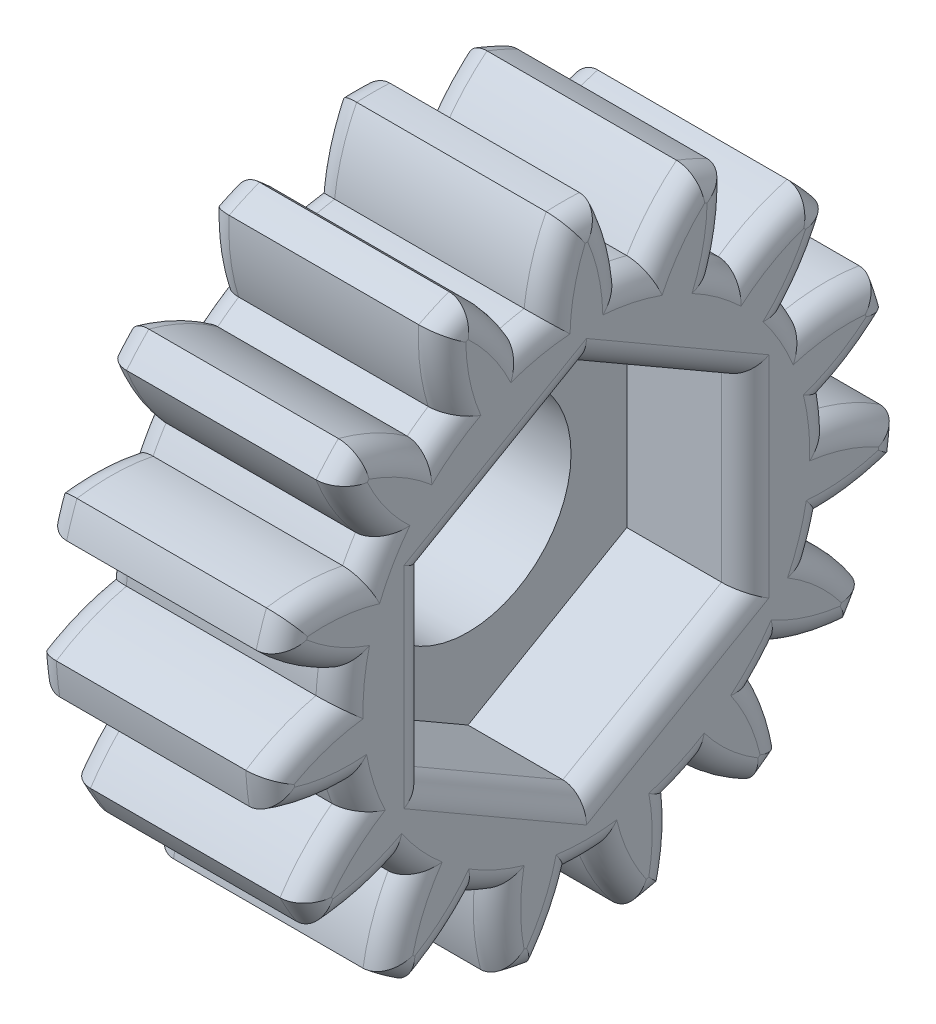
from build123d import *

# Parameters (mm, degrees)
SALIENTE_EXTRUIR1_DEPTH = 10
CORTAR_EXTRUIR1_DEPTH   = 5
CROQUIS1_4_R            = 4.35
CORTAR_EXTRUIR2_DEPTH   = 22.415605893
REDONDEO1_R             = 1


with BuildPart() as part:
    # Croquis1 → Saliente-Extruir1 (new body)
    with BuildSketch(Plane(origin=(0, 0, 0), x_dir=(0, 0, -1), z_dir=(1, 0, 0))):
        with BuildLine():
            ThreePointArc((-10.303317847, 1.631885231), (-10.374603782, 1.090414797), (-10.417453649, 0.545955612))
            ThreePointArc((-10.417453649, 0.545955612), (-11.954971432, 0.054051837), (-13.381635766, -0.701301814))
            ThreePointArc((-13.381635766, -0.701301814), (-13.326593398, -1.400681408), (-13.235023764, -2.096221832))
            ThreePointArc((-13.235023764, -2.096221832), (-11.682488615, -2.538448999), (-10.076296738, -2.699935574))
            ThreePointArc((-10.076296738, -2.699935574), (-9.921183814, -3.223588031), (-9.738877614, -3.738404858))
            ThreePointArc((-9.738877614, -3.738404858), (-10.943394711, -4.813146138), (-11.939487424, -6.083472697))
            ThreePointArc((-11.939487424, -6.083472697), (-11.604740411, -6.7), (-11.23818561, -7.298163069))
            ThreePointArc((-11.23818561, -7.298163069), (-9.640004184, -7.070684754), (-8.106992383, -6.564912989))
            ThreePointArc((-8.106992383, -6.564912989), (-7.752301033, -6.980203203), (-7.376361165, -7.376361165))
            ThreePointArc((-7.376361165, -7.376361165), (-8.039605626, -8.84810742), (-8.43289324, -10.413755884))
            ThreePointArc((-8.43289324, -10.413755884), (-7.876322381, -10.840827725), (-7.298163069, -11.23818561))
            ThreePointArc((-7.298163069, -11.23818561), (-5.930675452, -10.38033488), (-4.735915396, -9.294757309))
            ThreePointArc((-4.735915396, -9.294757309), (-4.242974976, -9.529877828), (-3.738404858, -9.738877614))
            ThreePointArc((-3.738404858, -9.738877614), (-3.745695692, -11.353150547), (-3.468175204, -12.943406072))
            ThreePointArc((-3.468175204, -12.943406072), (-2.786016657, -13.10717785), (-2.096221832, -13.235023764))
            ThreePointArc((-2.096221832, -13.235023764), (-1.195879057, -11.895130803), (-0.545955612, -10.417453649))
            ThreePointArc((-0.545955612, -10.417453649), (0, -10.43175), (0.545955612, -10.417453649))
            ThreePointArc((0.545955612, -10.417453649), (1.195879057, -11.895130803), (2.096221832, -13.235023764))
            ThreePointArc((2.096221832, -13.235023764), (2.786016657, -13.10717785), (3.468175204, -12.943406072))
            ThreePointArc((3.468175204, -12.943406072), (3.745695692, -11.353150547), (3.738404858, -9.738877614))
            ThreePointArc((3.738404858, -9.738877614), (4.242974976, -9.529877828), (4.735915396, -9.294757309))
            ThreePointArc((4.735915396, -9.294757309), (5.930675452, -10.38033488), (7.298163069, -11.23818561))
            ThreePointArc((7.298163069, -11.23818561), (7.876322381, -10.840827725), (8.43289324, -10.413755884))
            ThreePointArc((8.43289324, -10.413755884), (8.039605626, -8.84810742), (7.376361165, -7.376361165))
            ThreePointArc((7.376361165, -7.376361165), (7.752301033, -6.980203203), (8.106992383, -6.564912989))
            ThreePointArc((8.106992383, -6.564912989), (9.640004184, -7.070684754), (11.23818561, -7.298163069))
            ThreePointArc((11.23818561, -7.298163069), (11.604740411, -6.7), (11.939487424, -6.083472697))
            ThreePointArc((11.939487424, -6.083472697), (10.943394711, -4.813146138), (9.738877614, -3.738404858))
            ThreePointArc((9.738877614, -3.738404858), (9.921183814, -3.223588031), (10.076296738, -2.699935574))
            ThreePointArc((10.076296738, -2.699935574), (11.682488615, -2.538448999), (13.235023764, -2.096221832))
            ThreePointArc((13.235023764, -2.096221832), (13.326593398, -1.400681408), (13.381635766, -0.701301814))
            ThreePointArc((13.381635766, -0.701301814), (11.954971432, 0.054051837), (10.417453649, 0.545955612))
            ThreePointArc((10.417453649, 0.545955612), (10.374603782, 1.090414797), (10.303317847, 1.631885231))
            ThreePointArc((10.303317847, 1.631885231), (11.704964632, 2.43270765), (12.943406072, 3.468175204))
            ThreePointArc((12.943406072, 3.468175204), (12.744157318, 4.140827725), (12.509977715, 4.802130524))
            ThreePointArc((12.509977715, 4.802130524), (10.899424986, 4.911903759), (9.294757309, 4.735915396))
            ThreePointArc((9.294757309, 4.735915396), (9.034160506, 5.215875), (8.748801697, 5.681538254))
            ThreePointArc((8.748801697, 5.681538254), (9.703545929, 6.983227045), (10.413755884, 8.43289324))
            ThreePointArc((10.413755884, 8.43289324), (9.958140661, 8.966350125), (9.475230868, 9.475230868))
            ThreePointArc((9.475230868, 9.475230868), (7.959268941, 8.920442897), (6.564912989, 8.106992383))
            ThreePointArc((6.564912989, 8.106992383), (6.131628806, 8.439463031), (5.681538254, 8.748801697))
            ThreePointArc((5.681538254, 8.748801697), (6.02429598, 10.326283044), (6.083472697, 11.939487424))
            ThreePointArc((6.083472697, 11.939487424), (5.450271017, 12.241509132), (4.802130524, 12.509977715))
            ThreePointArc((4.802130524, 12.509977715), (3.642882988, 11.386556419), (2.699935574, 10.076296738))
            ThreePointArc((2.699935574, 10.076296738), (2.168882781, 10.203791234), (1.631885231, 10.303317847))
            ThreePointArc((1.631885231, 10.303317847), (1.303390528, 11.883830893), (0.701301814, 13.381635766))
            ThreePointArc((0.701301814, 13.381635766), (0, 13.4), (-0.701301814, 13.381635766))
            ThreePointArc((-0.701301814, 13.381635766), (-1.303390528, 11.883830893), (-1.631885231, 10.303317847))
            ThreePointArc((-1.631885231, 10.303317847), (-2.168882781, 10.203791234), (-2.699935574, 10.076296738))
            ThreePointArc((-2.699935574, 10.076296738), (-3.642882988, 11.386556419), (-4.802130524, 12.509977715))
            ThreePointArc((-4.802130524, 12.509977715), (-5.450271017, 12.241509132), (-6.083472697, 11.939487424))
            ThreePointArc((-6.083472697, 11.939487424), (-6.02429598, 10.326283044), (-5.681538254, 8.748801697))
            ThreePointArc((-5.681538254, 8.748801697), (-6.131628806, 8.439463031), (-6.564912989, 8.106992383))
            ThreePointArc((-6.564912989, 8.106992383), (-7.959268941, 8.920442897), (-9.475230868, 9.475230868))
            ThreePointArc((-9.475230868, 9.475230868), (-9.958140661, 8.966350125), (-10.413755884, 8.43289324))
            ThreePointArc((-10.413755884, 8.43289324), (-9.703545929, 6.983227045), (-8.748801697, 5.681538254))
            ThreePointArc((-8.748801697, 5.681538254), (-9.034160506, 5.215875), (-9.294757309, 4.735915396))
            ThreePointArc((-9.294757309, 4.735915396), (-10.899424986, 4.911903759), (-12.509977715, 4.802130524))
            ThreePointArc((-12.509977715, 4.802130524), (-12.744157318, 4.140827725), (-12.943406072, 3.468175204))
            ThreePointArc((-12.943406072, 3.468175204), (-11.704964632, 2.43270765), (-10.303317847, 1.631885231))
        make_face()
    extrude(amount=-SALIENTE_EXTRUIR1_DEPTH)

    # Croquis1_3 → Cortar-Extruir1 (cut)
    with BuildSketch(Plane(origin=(0, 0, 0), x_dir=(0, 0, -1), z_dir=(1, 0, 0))):
        Polygon((-6.703036625, -3.87), (0, -7.74), (6.703036625, -3.87), (6.703036625, 3.87), (0, 7.74), (-6.703036625, 3.87), align=None)
    extrude(amount=-CORTAR_EXTRUIR1_DEPTH, mode=Mode.SUBTRACT)

    # Croquis1_4 → Cortar-Extruir2 (cut, through all)
    with BuildSketch(Plane(origin=(0, 0, 0), x_dir=(0, 0, -1), z_dir=(1, 0, 0))):
        Circle(CROQUIS1_4_R)
    extrude(amount=-CORTAR_EXTRUIR2_DEPTH, mode=Mode.SUBTRACT)

    # Redondeo1
    redondeo1_edges = [part.edges().sort_by_distance(p)[0] for p in [
        (-10, 10.326283044, 6.02429598),
        (-10, 8.439463031, 6.131628806),
        (-10, 8.920442897, 7.959268941),
        (-10, 8.966350125, 9.958140661),
        (-10, 6.983227045, 9.703545929),
        (-10, 5.215875, 9.034160506),
        (-10, 4.911903759, 10.899424986),
        (-10, 4.140827725, 12.744157318),
        (-10, 2.43270765, 11.704964632),
        (-10, 1.090414797, 10.374603782),
        (-10, 0.054051837, 11.954971432),
        (-10, -1.400681408, 13.326593398),
        (-10, -2.538448999, 11.682488615),
        (-10, -3.223588031, 9.921183814),
        (-10, -4.813146138, 10.943394711),
        (-10, -6.7, 11.604740411),
        (-10, -7.070684754, 9.640004184),
        (-10, -6.980203203, 7.752301033),
        (-10, -8.84810742, 8.039605626),
        (-10, -10.840827725, 7.876322381),
        (-10, -10.38033488, 5.930675452),
        (-10, -9.529877828, 4.242974976),
        (-10, -11.353150547, 3.745695692),
        (-10, -13.10717785, 2.786016657),
        (-10, -11.895130803, 1.195879057),
        (-10, -10.43175, 0),
        (-10, -11.895130803, -1.195879057),
        (-10, -13.10717785, -2.786016657),
        (-10, -11.353150547, -3.745695692),
        (-10, -9.529877828, -4.242974976),
        (-10, -10.38033488, -5.930675452),
        (-10, -10.840827725, -7.876322381),
        (-10, -8.84810742, -8.039605626),
        (-10, -6.980203203, -7.752301033),
        (-10, -7.070684754, -9.640004184),
        (-10, -6.7, -11.604740411),
        (-10, -4.813146138, -10.943394711),
        (-10, -3.223588031, -9.921183814),
        (-10, -2.538448999, -11.682488615),
        (-10, -1.400681408, -13.326593398),
        (-10, 0.054051837, -11.954971432),
        (-10, 1.090414797, -10.374603782),
        (-10, 2.43270765, -11.704964632),
        (-10, 4.140827725, -12.744157318),
        (-10, 4.911903759, -10.899424986),
        (-10, 5.215875, -9.034160506),
        (-10, 6.983227045, -9.703545929),
        (-10, 8.966350125, -9.958140661),
        (-10, 8.920442897, -7.959268941),
        (-10, 8.439463031, -6.131628806),
        (-10, 10.326283044, -6.02429598),
        (-10, 12.241509132, -5.450271017),
        (-10, 11.386556419, -3.642882988),
        (-10, 10.203791234, -2.168882781),
        (-10, 11.883830893, -1.303390528),
        (-10, 13.4, 0),
        (-10, 11.883830893, 1.303390528),
        (-10, 10.203791234, 2.168882781),
        (-10, 11.386556419, 3.642882988),
        (-10, 12.241509132, 5.450271017),
        (-10, 0, 4.35),
        (0, 11.386556419, 3.642882988),
        (0, 10.203791234, 2.168882781),
        (0, 11.883830893, 1.303390528),
        (0, 13.4, 0),
        (0, 11.883830893, -1.303390528),
        (0, 10.203791234, -2.168882781),
        (0, 11.386556419, -3.642882988),
        (0, 12.241509132, -5.450271017),
        (0, 10.326283044, -6.02429598),
        (0, 8.439463031, -6.131628806),
        (0, 8.920442897, -7.959268941),
        (0, 8.966350125, -9.958140661),
        (0, 6.983227045, -9.703545929),
        (0, 5.215875, -9.034160506),
        (0, 4.911903759, -10.899424986),
        (0, 4.140827725, -12.744157318),
        (0, 2.43270765, -11.704964632),
        (0, 1.090414797, -10.374603782),
        (0, 0.054051837, -11.954971432),
        (0, -1.400681408, -13.326593398),
        (0, -2.538448999, -11.682488615),
        (0, -3.223588031, -9.921183814),
        (0, -4.813146138, -10.943394711),
        (0, -6.7, -11.604740411),
        (0, -7.070684754, -9.640004184),
        (0, -6.980203203, -7.752301033),
        (0, -8.84810742, -8.039605626),
        (0, -10.840827725, -7.876322381),
        (0, -10.38033488, -5.930675452),
        (0, -9.529877828, -4.242974976),
        (0, -11.353150547, -3.745695692),
        (0, -13.10717785, -2.786016657),
        (0, -11.895130803, -1.195879057),
        (0, -10.43175, 0),
        (0, -11.895130803, 1.195879057),
        (0, -13.10717785, 2.786016657),
        (0, -11.353150547, 3.745695692),
        (0, -9.529877828, 4.242974976),
        (0, -10.38033488, 5.930675452),
        (0, -10.840827725, 7.876322381),
        (0, -8.84810742, 8.039605626),
        (0, -6.980203203, 7.752301033),
        (0, -7.070684754, 9.640004184),
        (0, -6.7, 11.604740411),
        (0, -4.813146138, 10.943394711),
        (0, -3.223588031, 9.921183814),
        (0, -2.538448999, 11.682488615),
        (0, -1.400681408, 13.326593398),
        (0, 0.054051837, 11.954971432),
        (0, 1.090414797, 10.374603782),
        (0, 2.43270765, 11.704964632),
        (0, 4.140827725, 12.744157318),
        (0, 4.911903759, 10.899424986),
        (0, 5.215875, 9.034160506),
        (0, 6.983227045, 9.703545929),
        (0, 8.966350125, 9.958140661),
        (0, 8.920442897, 7.959268941),
        (0, 8.439463031, 6.131628806),
        (0, 10.326283044, 6.02429598),
        (0, 12.241509132, 5.450271017),
        (0, -5.805, 3.351518313),
        (0, -5.805, -3.351518313),
        (0, 0, -6.703036625),
        (0, 5.805, -3.351518313),
        (0, 5.805, 3.351518313),
        (0, 0, 6.703036625),
    ]]
    fillet(redondeo1_edges, radius=REDONDEO1_R)


solid = part.part
